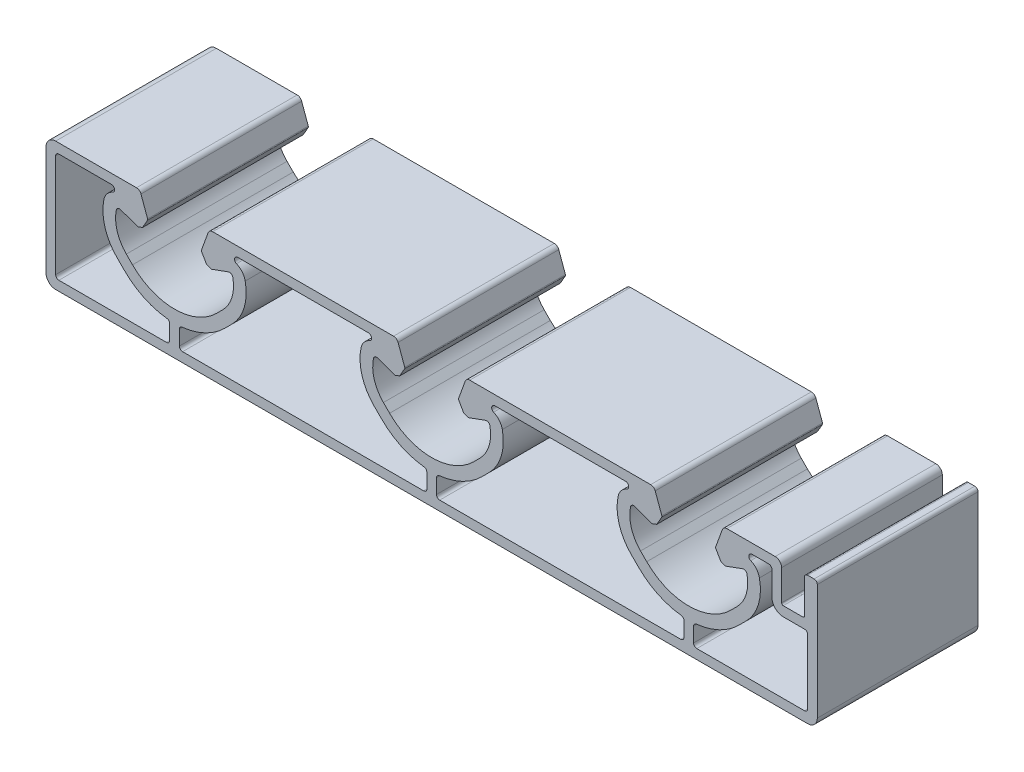
from build123d import *

# Parameters (mm, degrees)
MAIN_EXTRUSION_DEPTH = 25


with BuildPart() as part:
    # Sk Main Extrusion → Main Extrusion (new body)
    with BuildSketch(Plane.XY):
        with BuildLine():
            Line((-45.926823816, 10), (-58.5, 10))
            ThreePointArc((-58.5, 10), (-59.560660172, 9.560660172), (-60, 8.5))
            Line((-60, 8.5), (-60, -8.5))
            ThreePointArc((-60, -8.5), (-59.560660172, -9.560660172), (-58.5, -10))
            Line((-58.5, -10), (58.5, -10))
            ThreePointArc((58.5, -10), (59.560660172, -9.560660172), (60, -8.5))
            Line((60, -8.5), (60, 9.5))
            ThreePointArc((60, 9.5), (59.853553391, 9.853553391), (59.5, 10))
            Line((59.5, 10), (58.5, 10))
            ThreePointArc((58.5, 10), (58.146446609, 9.853553391), (58, 9.5))
            Line((58, 9.5), (58, 4.25))
            ThreePointArc((58, 4.25), (57.926776695, 4.073223305), (57.75, 4))
            Line((57.75, 4), (54.694, 4))
            ThreePointArc((54.694, 4), (54.517223305, 4.073223305), (54.444, 4.25))
            Line((54.444, 4.25), (54.444, 9))
            ThreePointArc((54.444, 9), (54.151106781, 9.707106781), (53.444, 10))
            Line((53.444, 10), (45.926823816, 10))
            ThreePointArc((45.926823816, 10), (45.496641489, 9.864364033), (45.222054351, 9.506515107))
            Line((45.222054351, 9.506515107), (44.190076845, 6.671180212))
            ThreePointArc((44.190076845, 6.671180212), (44.175951325, 6.563886241), (44.208493649, 6.460675177))
            Line((44.208493649, 6.460675177), (44.987558066, 5.111296024))
            Line((44.987558066, 5.111296024), (45.718509166, 4.845251581))
            Line((45.718509166, 4.845251581), (48.396186179, 5.81984631))
            ThreePointArc((48.396186179, 5.81984631), (48.811074612, 5.786489799), (49.056960151, 5.450654467))
            ThreePointArc((49.056960151, 5.450654467), (48.933433013, 2.665882372), (47.504160339, 0.272684887))
            Line((47.504160339, 0.272684887), (46.540737726, -0.690737726))
            ThreePointArc((46.540737726, -0.690737726), (40, -3.4), (33.459262274, -0.690737726))
            Line((33.459262274, -0.690737726), (32.495839661, 0.272684887))
            ThreePointArc((32.495839661, 0.272684887), (31.066566987, 2.665882372), (30.943039849, 5.450654467))
            ThreePointArc((30.943039849, 5.450654467), (31.188925388, 5.786489799), (31.603813821, 5.81984631))
            Line((31.603813821, 5.81984631), (34.281490834, 4.845251581))
            Line((34.281490834, 4.845251581), (35.012441934, 5.111296024))
            Line((35.012441934, 5.111296024), (35.791506351, 6.460675177))
            ThreePointArc((35.791506351, 6.460675177), (35.824048675, 6.563886241), (35.809923155, 6.671180212))
            Line((35.809923155, 6.671180212), (34.777945649, 9.506515107))
            ThreePointArc((34.777945649, 9.506515107), (34.503358511, 9.864364033), (34.073176184, 10))
            Line((34.073176184, 10), (5.926823816, 10))
            ThreePointArc((5.926823816, 10), (5.496641489, 9.864364033), (5.222054351, 9.506515107))
            Line((5.222054351, 9.506515107), (4.190076845, 6.671180212))
            ThreePointArc((4.190076845, 6.671180212), (4.175951325, 6.563886241), (4.208493649, 6.460675177))
            Line((4.208493649, 6.460675177), (4.987558066, 5.111296024))
            Line((4.987558066, 5.111296024), (5.718509166, 4.845251581))
            Line((5.718509166, 4.845251581), (8.396186179, 5.81984631))
            ThreePointArc((8.396186179, 5.81984631), (8.811074612, 5.786489799), (9.056960151, 5.450654467))
            ThreePointArc((9.056960151, 5.450654467), (8.933433013, 2.665882372), (7.504160339, 0.272684887))
            Line((7.504160339, 0.272684887), (6.540737726, -0.690737726))
            ThreePointArc((6.540737726, -0.690737726), (0, -3.4), (-6.540737726, -0.690737726))
            Line((-6.540737726, -0.690737726), (-7.504160339, 0.272684887))
            ThreePointArc((-7.504160339, 0.272684887), (-8.933433013, 2.665882372), (-9.056960151, 5.450654467))
            ThreePointArc((-9.056960151, 5.450654467), (-8.811074612, 5.786489799), (-8.396186179, 5.81984631))
            Line((-8.396186179, 5.81984631), (-5.718509166, 4.845251581))
            Line((-5.718509166, 4.845251581), (-4.987558066, 5.111296024))
            Line((-4.987558066, 5.111296024), (-4.208493649, 6.460675177))
            ThreePointArc((-4.208493649, 6.460675177), (-4.175951325, 6.563886241), (-4.190076845, 6.671180212))
            Line((-4.190076845, 6.671180212), (-5.222054351, 9.506515107))
            ThreePointArc((-5.222054351, 9.506515107), (-5.496641489, 9.864364033), (-5.926823816, 10))
            Line((-5.926823816, 10), (-34.073176184, 10))
            ThreePointArc((-34.073176184, 10), (-34.503358511, 9.864364033), (-34.777945649, 9.506515107))
            Line((-34.777945649, 9.506515107), (-35.809923155, 6.671180212))
            ThreePointArc((-35.809923155, 6.671180212), (-35.824048675, 6.563886241), (-35.791506351, 6.460675177))
            Line((-35.791506351, 6.460675177), (-35.012441934, 5.111296024))
            Line((-35.012441934, 5.111296024), (-34.281490834, 4.845251581))
            Line((-34.281490834, 4.845251581), (-31.603813821, 5.81984631))
            ThreePointArc((-31.603813821, 5.81984631), (-31.188925388, 5.786489799), (-30.943039849, 5.450654467))
            ThreePointArc((-30.943039849, 5.450654467), (-31.066566987, 2.665882372), (-32.495839661, 0.272684887))
            Line((-32.495839661, 0.272684887), (-33.459262274, -0.690737726))
            ThreePointArc((-33.459262274, -0.690737726), (-40, -3.4), (-46.540737726, -0.690737726))
            Line((-46.540737726, -0.690737726), (-47.504160339, 0.272684887))
            ThreePointArc((-47.504160339, 0.272684887), (-48.933433013, 2.665882372), (-49.056960151, 5.450654467))
            ThreePointArc((-49.056960151, 5.450654467), (-48.811074612, 5.786489799), (-48.396186179, 5.81984631))
            Line((-48.396186179, 5.81984631), (-45.718509166, 4.845251581))
            Line((-45.718509166, 4.845251581), (-44.987558066, 5.111296024))
            Line((-44.987558066, 5.111296024), (-44.208493649, 6.460675177))
            ThreePointArc((-44.208493649, 6.460675177), (-44.175951325, 6.563886241), (-44.190076845, 6.671180212))
            Line((-44.190076845, 6.671180212), (-45.222054351, 9.506515107))
            ThreePointArc((-45.222054351, 9.506515107), (-45.496641489, 9.864364033), (-45.926823816, 10))
        make_face()
        with BuildLine():
            Line((-58.5, 8), (-58.5, -8))
            ThreePointArc((-58.5, -8), (-58.353553391, -8.353553391), (-58, -8.5))
            Line((-58, -8.5), (-41.25, -8.5))
            ThreePointArc((-41.25, -8.5), (-40.896446609, -8.353553391), (-40.75, -8))
            Line((-40.75, -8), (-40.75, -5.732160076))
            ThreePointArc((-40.75, -5.732160076), (-40.877806316, -5.398286055), (-41.195887446, -5.235096869))
            ThreePointArc((-41.195887446, -5.235096869), (-44.775678965, -4.214707242), (-47.813529932, -2.063529932))
            Line((-47.813529932, -2.063529932), (-48.949307842, -0.927752022))
            ThreePointArc((-48.949307842, -0.927752022), (-50.830369733, 2.222659643), (-50.991848014, 5.888367249))
            ThreePointArc((-50.991848014, 5.888367249), (-50.519715441, 6.880283822), (-49.641376427, 7.540077905))
            ThreePointArc((-49.641376427, 7.540077905), (-49.347640313, 8.100097334), (-49.837518383, 8.5))
            Line((-49.837518383, 8.5), (-58, 8.5))
            ThreePointArc((-58, 8.5), (-58.353553391, 8.353553391), (-58.5, 8))
        make_face(mode=Mode.SUBTRACT)
        with BuildLine():
            Line((-39.25, -5.732160076), (-39.25, -8))
            ThreePointArc((-39.25, -8), (-39.103553391, -8.353553391), (-38.75, -8.5))
            Line((-38.75, -8.5), (-1.25, -8.5))
            ThreePointArc((-1.25, -8.5), (-0.896446609, -8.353553391), (-0.75, -8))
            Line((-0.75, -8), (-0.75, -5.732160076))
            ThreePointArc((-0.75, -5.732160076), (-0.877806316, -5.398286055), (-1.195887446, -5.235096869))
            ThreePointArc((-1.195887446, -5.235096869), (-4.775678965, -4.214707242), (-7.813529932, -2.063529932))
            Line((-7.813529932, -2.063529932), (-8.949307842, -0.927752022))
            ThreePointArc((-8.949307842, -0.927752022), (-10.830369733, 2.222659643), (-10.991848014, 5.888367249))
            ThreePointArc((-10.991848014, 5.888367249), (-10.519715441, 6.880283822), (-9.641376427, 7.540077905))
            ThreePointArc((-9.641376427, 7.540077905), (-9.347640313, 8.100097334), (-9.837518383, 8.5))
            Line((-9.837518383, 8.5), (-30.162481617, 8.5))
            ThreePointArc((-30.162481617, 8.5), (-30.652359687, 8.100097334), (-30.358623573, 7.540077905))
            ThreePointArc((-30.358623573, 7.540077905), (-29.480284559, 6.880283822), (-29.008151986, 5.888367249))
            ThreePointArc((-29.008151986, 5.888367249), (-29.169630267, 2.222659643), (-31.050692158, -0.927752022))
            Line((-31.050692158, -0.927752022), (-32.186470068, -2.063529932))
            ThreePointArc((-32.186470068, -2.063529932), (-35.224321035, -4.214707242), (-38.804112554, -5.235096869))
            ThreePointArc((-38.804112554, -5.235096869), (-39.122193684, -5.398286055), (-39.25, -5.732160076))
        make_face(mode=Mode.SUBTRACT)
        with BuildLine():
            Line((8.949307842, -0.927752022), (7.813529932, -2.063529932))
            ThreePointArc((7.813529932, -2.063529932), (4.775678965, -4.214707242), (1.195887446, -5.235096869))
            ThreePointArc((1.195887446, -5.235096869), (0.877806316, -5.398286055), (0.75, -5.732160076))
            Line((0.75, -5.732160076), (0.75, -8))
            ThreePointArc((0.75, -8), (0.896446609, -8.353553391), (1.25, -8.5))
            Line((1.25, -8.5), (38.75, -8.5))
            ThreePointArc((38.75, -8.5), (39.103553391, -8.353553391), (39.25, -8))
            Line((39.25, -8), (39.25, -5.732160076))
            ThreePointArc((39.25, -5.732160076), (39.122193684, -5.398286055), (38.804112554, -5.235096869))
            ThreePointArc((38.804112554, -5.235096869), (35.224321035, -4.214707242), (32.186470068, -2.063529932))
            Line((32.186470068, -2.063529932), (31.050692158, -0.927752022))
            ThreePointArc((31.050692158, -0.927752022), (29.169630267, 2.222659643), (29.008151986, 5.888367249))
            ThreePointArc((29.008151986, 5.888367249), (29.480284559, 6.880283822), (30.358623573, 7.540077905))
            ThreePointArc((30.358623573, 7.540077905), (30.652359687, 8.100097334), (30.162481617, 8.5))
            Line((30.162481617, 8.5), (9.837518383, 8.5))
            ThreePointArc((9.837518383, 8.5), (9.347640313, 8.100097334), (9.641376427, 7.540077905))
            ThreePointArc((9.641376427, 7.540077905), (10.519715441, 6.880283822), (10.991848014, 5.888367249))
            ThreePointArc((10.991848014, 5.888367249), (10.830369733, 2.222659643), (8.949307842, -0.927752022))
        make_face(mode=Mode.SUBTRACT)
        with BuildLine():
            Line((40.75, -5.732160076), (40.75, -8))
            ThreePointArc((40.75, -8), (40.896446609, -8.353553391), (41.25, -8.5))
            Line((41.25, -8.5), (58, -8.5))
            ThreePointArc((58, -8.5), (58.353553391, -8.353553391), (58.5, -8))
            Line((58.5, -8), (58.5, 2))
            ThreePointArc((58.5, 2), (58.353553391, 2.353553391), (58, 2.5))
            Line((58, 2.5), (54.694, 2.5))
            ThreePointArc((54.694, 2.5), (53.456563133, 3.012563133), (52.944, 4.25))
            Line((52.944, 4.25), (52.944, 8))
            ThreePointArc((52.944, 8), (52.797553391, 8.353553391), (52.444, 8.5))
            Line((52.444, 8.5), (49.837518383, 8.5))
            ThreePointArc((49.837518383, 8.5), (49.347640313, 8.100097334), (49.641376427, 7.540077905))
            ThreePointArc((49.641376427, 7.540077905), (50.519715441, 6.880283822), (50.991848014, 5.888367249))
            ThreePointArc((50.991848014, 5.888367249), (50.830369733, 2.222659643), (48.949307842, -0.927752022))
            Line((48.949307842, -0.927752022), (47.813529932, -2.063529932))
            ThreePointArc((47.813529932, -2.063529932), (44.775678965, -4.214707242), (41.195887446, -5.235096869))
            ThreePointArc((41.195887446, -5.235096869), (40.877806316, -5.398286055), (40.75, -5.732160076))
        make_face(mode=Mode.SUBTRACT)
    extrude(amount=-MAIN_EXTRUSION_DEPTH)


solid = part.part
